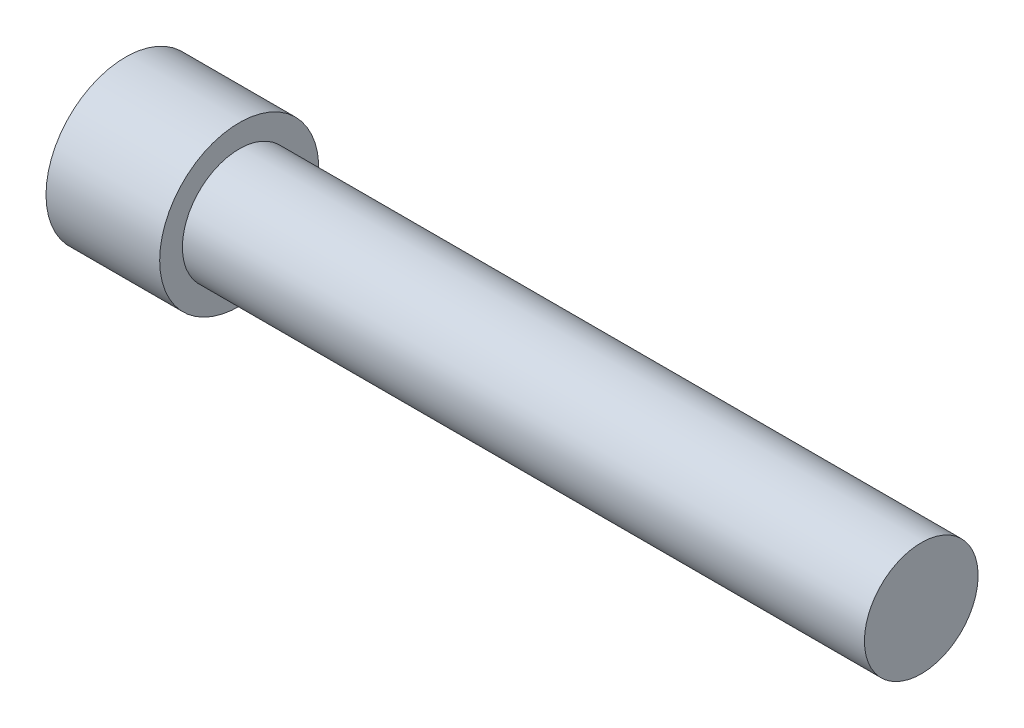
from build123d import *


with BuildPart() as part:
    # Sketch1 → Revolve1 (revolve)
    with BuildSketch(Plane.XY):
        Polygon((0, 0), (35, 0), (35, 2.5), (5, 2.5), (5, 3.5), (0, 3.5), align=None)
    revolve(axis=Axis((0, 0, 0), (1, 0, 0)))


solid = part.part
